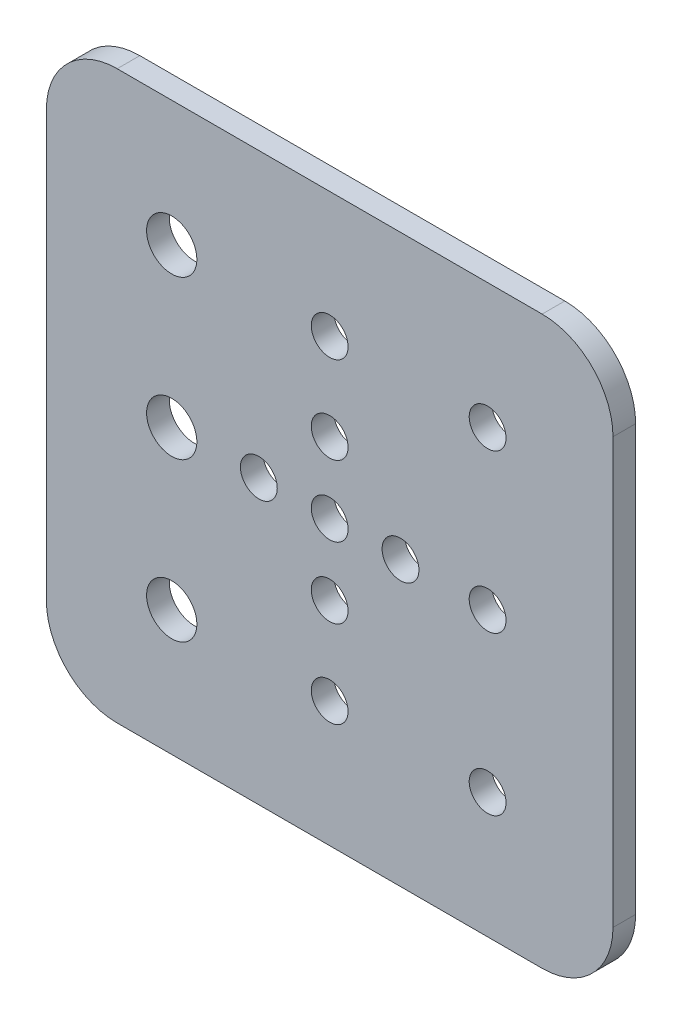
from build123d import *

# Parameters (mm, degrees)
SKETCH1_W           = 80
SKETCH1_H           = 80
SKETCH1_R           = 2.6
SKETCH1_R_2         = 3.55
BOSS_EXTRUDE1_DEPTH = 3.2
FILLET1_R           = 10


with BuildPart() as part:
    # Sketch1 → Boss-Extrude1 (new body)
    with BuildSketch(Plane.XY):
        Rectangle(SKETCH1_W, SKETCH1_H)
        Circle(SKETCH1_R, mode=Mode.SUBTRACT)
        with Locations((0, 10)):
            Circle(SKETCH1_R, mode=Mode.SUBTRACT)
        with Locations((0, 22.3)):
            Circle(SKETCH1_R, mode=Mode.SUBTRACT)
        with Locations((0, -10)):
            Circle(SKETCH1_R, mode=Mode.SUBTRACT)
        with Locations((0, -22.3)):
            Circle(SKETCH1_R, mode=Mode.SUBTRACT)
        with Locations((10, 0)):
            Circle(SKETCH1_R, mode=Mode.SUBTRACT)
        with Locations((-10, 0)):
            Circle(SKETCH1_R, mode=Mode.SUBTRACT)
        with Locations((-22.3, 0)):
            Circle(SKETCH1_R_2, mode=Mode.SUBTRACT)
        with Locations((22.3, 0)):
            Circle(SKETCH1_R, mode=Mode.SUBTRACT)
        with Locations((22.3, 22.3)):
            Circle(SKETCH1_R, mode=Mode.SUBTRACT)
        with Locations((22.3, -22.3)):
            Circle(SKETCH1_R, mode=Mode.SUBTRACT)
        with Locations((-22.3, -22.3)):
            Circle(SKETCH1_R_2, mode=Mode.SUBTRACT)
        with Locations((-22.3, 22.3)):
            Circle(SKETCH1_R_2, mode=Mode.SUBTRACT)
    extrude(amount=BOSS_EXTRUDE1_DEPTH)

    # Fillet1
    fillet1_edges = [part.edges().sort_by_distance(p)[0] for p in [
        (40, -40, 1.6),
        (-40, -40, 1.6),
        (-40, 40, 1.6),
        (40, 40, 1.6),
    ]]
    fillet(fillet1_edges, radius=FILLET1_R)


solid = part.part
